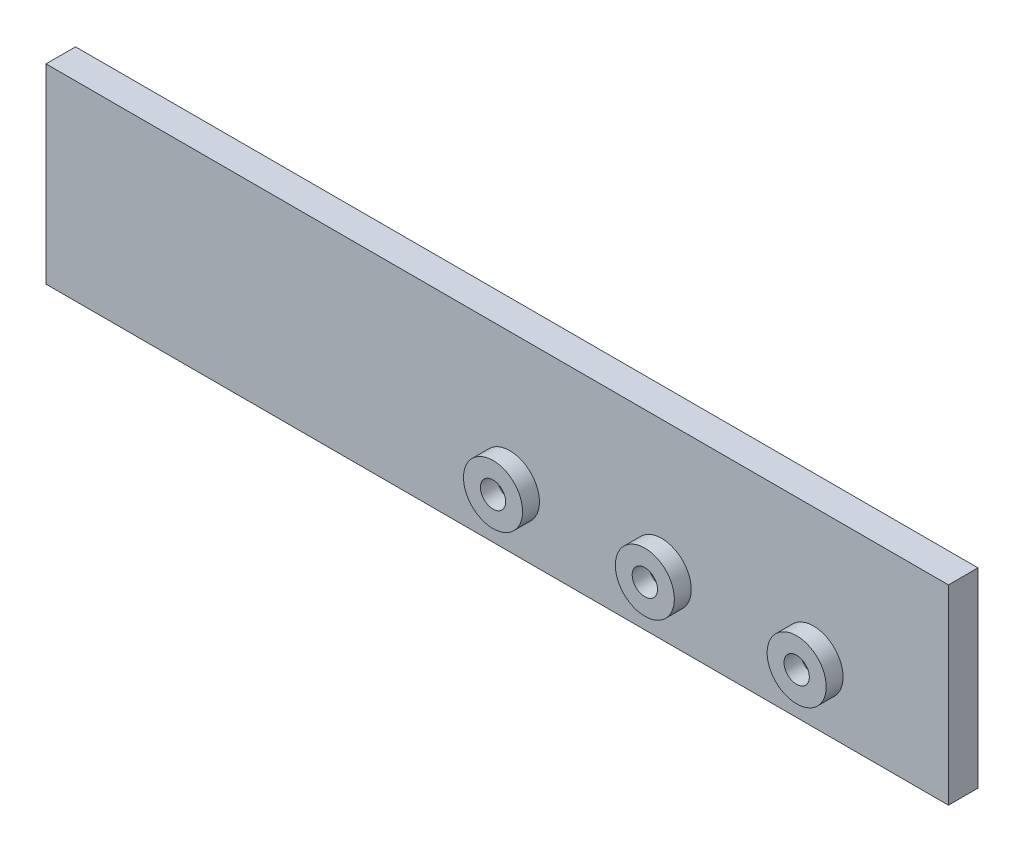
from build123d import *

# Parameters (mm, degrees)
ESBO_O1_W                = 107
ESBO_O1_H                = 22.62
RESSALTO_EXTRUS_O1_DEPTH = 3.5
ESBO_O1_4_R              = 3.5
RESSALTO_EXTRUS_O2_DEPTH = 5.5
ESBO_O1_7_R              = 1.5
CORTE_EXTRUS_O1_DEPTH    = 5.5
ESBO_O1_9_R              = 1.5
RESSALTO_EXTRUS_O4_DEPTH = 3.5


with BuildPart() as part:
    # Esboço1 → Ressalto-extrusão1 (new body)
    with BuildSketch(Plane.XY):
        with Locations((12.82231405, 21.961694215)):
            Rectangle(ESBO_O1_W, ESBO_O1_H)
    extrude(amount=RESSALTO_EXTRUS_O1_DEPTH)

    # Esboço1<4> → Ressalto-extrusão2 (add)
    with BuildSketch(Plane.XY):
        with Locations((14.32231405, 17.551694215)):
            Circle(ESBO_O1_4_R)
        with Locations((32.32231405, 17.551694215)):
            Circle(ESBO_O1_4_R)
        with Locations((50.32231405, 17.551694215)):
            Circle(ESBO_O1_4_R)
    extrude(amount=RESSALTO_EXTRUS_O2_DEPTH)

    # Esboço1<7> → Corte-extrusão1 (cut)
    with BuildSketch(Plane.XY):
        with Locations((14.32231405, 17.551694215)):
            Circle(ESBO_O1_7_R)
        with Locations((32.32231405, 17.551694215)):
            Circle(ESBO_O1_7_R)
        with Locations((50.32231405, 17.551694215)):
            Circle(ESBO_O1_7_R)
    extrude(amount=CORTE_EXTRUS_O1_DEPTH, mode=Mode.SUBTRACT)

    # Esboço1<9> → Ressalto-extrusão4 (add)
    with BuildSketch(Plane.XY):
        with Locations((14.32231405, 17.551694215)):
            Circle(ESBO_O1_9_R)
        with Locations((32.32231405, 17.551694215)):
            Circle(ESBO_O1_9_R)
        with Locations((50.32231405, 17.551694215)):
            Circle(ESBO_O1_9_R)
    extrude(amount=RESSALTO_EXTRUS_O4_DEPTH)


solid = part.part
